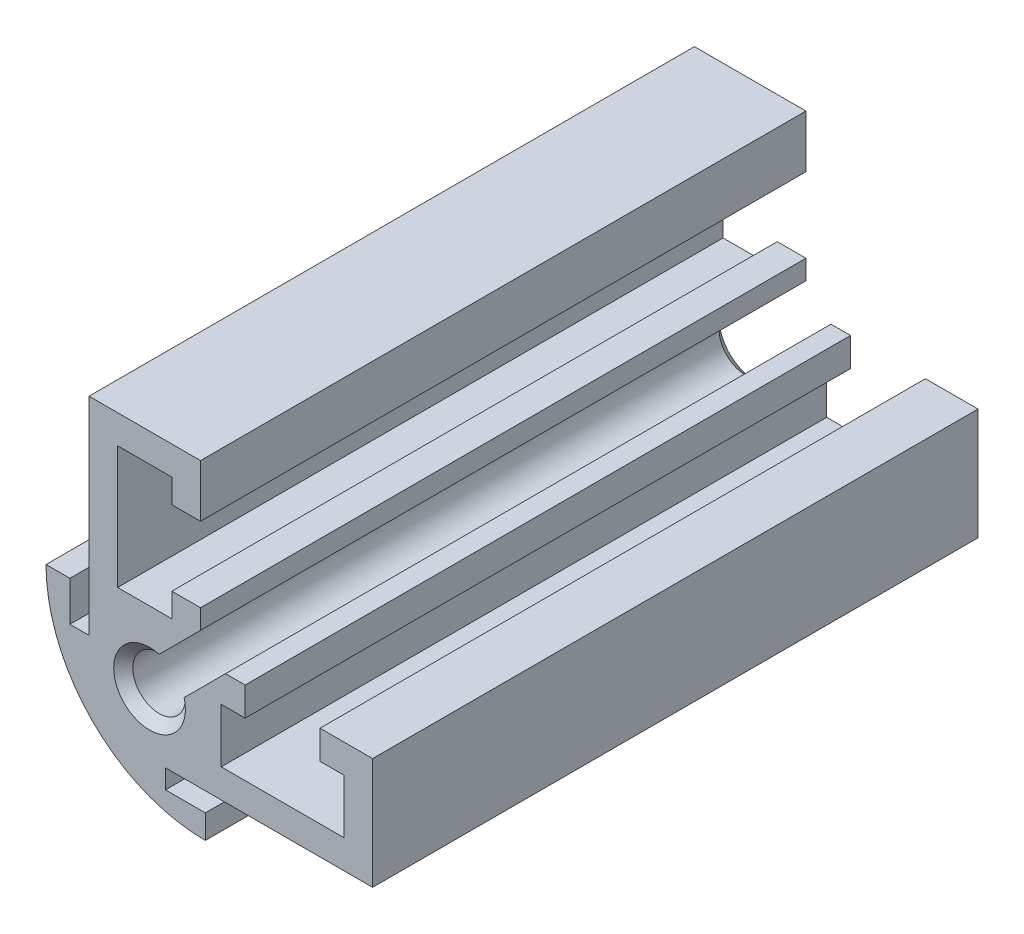
from build123d import *

# Parameters (mm, degrees)
EXTRUDE1_DEPTH     = 19
CUT_EXTRUDE1_DEPTH = 39
CUT_EXTRUDE2_DEPTH = 39


with BuildPart() as part:
    # Sketch1 → Extrude1 (new body, symmetric)
    with BuildSketch(Plane.XY):
        with BuildLine():
            Line((-10.25, 10.25), (10.25, 10.25))
            Line((10.25, 10.25), (10.25, -10.25))
            Line((10.25, -10.25), (-0.25, -10.25))
            ThreePointArc((-0.25, -10.25), (-7.321067812, -7.321067812), (-10.25, -0.25))
            Line((-10.25, -0.25), (-10.25, 10.25))
        make_face()
    extrude(amount=EXTRUDE1_DEPTH, both=True)

    # Sketch2 → Cut-Extrude1 (cut, through all)
    with BuildSketch(Plane.XY.offset(19)):
        Polygon((10.25, -7.55), (-2.75, -7.55), (-2.75, -8.75), (-0.25, -8.75), (-0.25, -10.25), (10.25, -10.25), align=None)
        Polygon((-7.55, 10.25), (-7.55, -2.75), (-8.75, -2.75), (-8.75, -0.25), (-10.25, -0.25), (-10.25, 10.25), align=None)
    extrude(amount=-CUT_EXTRUDE1_DEPTH, mode=Mode.SUBTRACT)

    # Sketch3 → Cut-Extrude2 (cut, through all)
    with BuildSketch(Plane.XY.offset(19)):
        with BuildLine():
            Line((-0.55, 10.25), (-0.55, 6.95))
            Line((-0.55, 6.95), (-2.35, 6.95))
            Line((-2.35, 6.95), (-2.35, 8.45))
            Line((-2.35, 8.45), (-5.75, 8.45))
            Line((-5.75, 8.45), (-5.75, 0.75))
            Line((-5.75, 0.75), (-2.35, 0.75))
            Line((-2.35, 0.75), (-2.35, 2.25))
            Line((-2.35, 2.25), (-0.55, 2.25))
            Line((-0.55, 2.25), (-0.55, 1.02))
            Line((-0.55, 1.02), (-3.821715344, -2.251715344))
            ThreePointArc((-3.821715344, -2.251715344), (-4.810660172, -4.810660172), (-2.251715344, -3.821715344))
            Line((-2.251715344, -3.821715344), (1.02, -0.55))
            Line((1.02, -0.55), (2.25, -0.55))
            Line((2.25, -0.55), (2.25, -2.35))
            Line((2.25, -2.35), (0.75, -2.35))
            Line((0.75, -2.35), (0.75, -5.75))
            Line((0.75, -5.75), (8.45, -5.75))
            Line((8.45, -5.75), (8.45, -2.35))
            Line((8.45, -2.35), (6.95, -2.35))
            Line((6.95, -2.35), (6.95, -0.55))
            Line((6.95, -0.55), (10.25, -0.55))
            Line((10.25, -0.55), (10.25, 10.25))
            Line((10.25, 10.25), (-0.55, 10.25))
        make_face()
    extrude(amount=-CUT_EXTRUDE2_DEPTH, mode=Mode.SUBTRACT)

    # Esboço1 → Furo roscado de M41 (revolve, cut)
    with BuildSketch(Plane(origin=(-3.75, -3.75, 19), x_dir=(0, -1, 0), z_dir=(1, 0, 0))):
        Polygon((0, 0), (0, 38), (2.25, 38), (1.65, 37.4), (1.65, 0.6), (2.25, 0), align=None)
    revolve(axis=Axis((-3.75, -3.75, 25.35), (0, 0, -1)), mode=Mode.SUBTRACT)


solid = part.part
